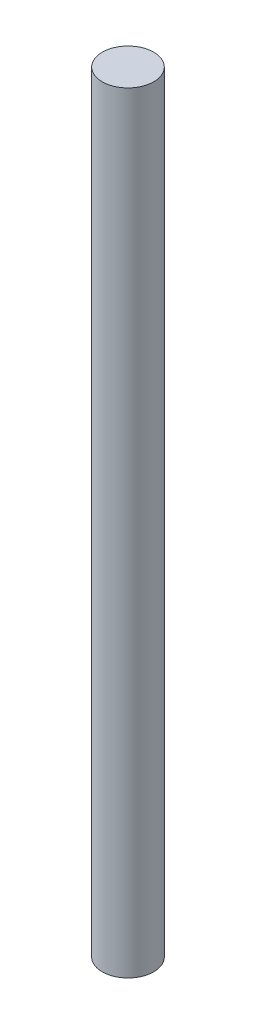
from build123d import *

# Parameters (mm, degrees)
SKETCH1_R           = 2.5
BOSS_EXTRUDE1_DEPTH = 75


with BuildPart() as part:
    # Sketch1 → Boss-Extrude1 (new body)
    with BuildSketch(Plane(origin=(0, 0, 0), x_dir=(1, 0, 0), z_dir=(0, 1, 0))):
        Circle(SKETCH1_R)
    extrude(amount=BOSS_EXTRUDE1_DEPTH)


solid = part.part
